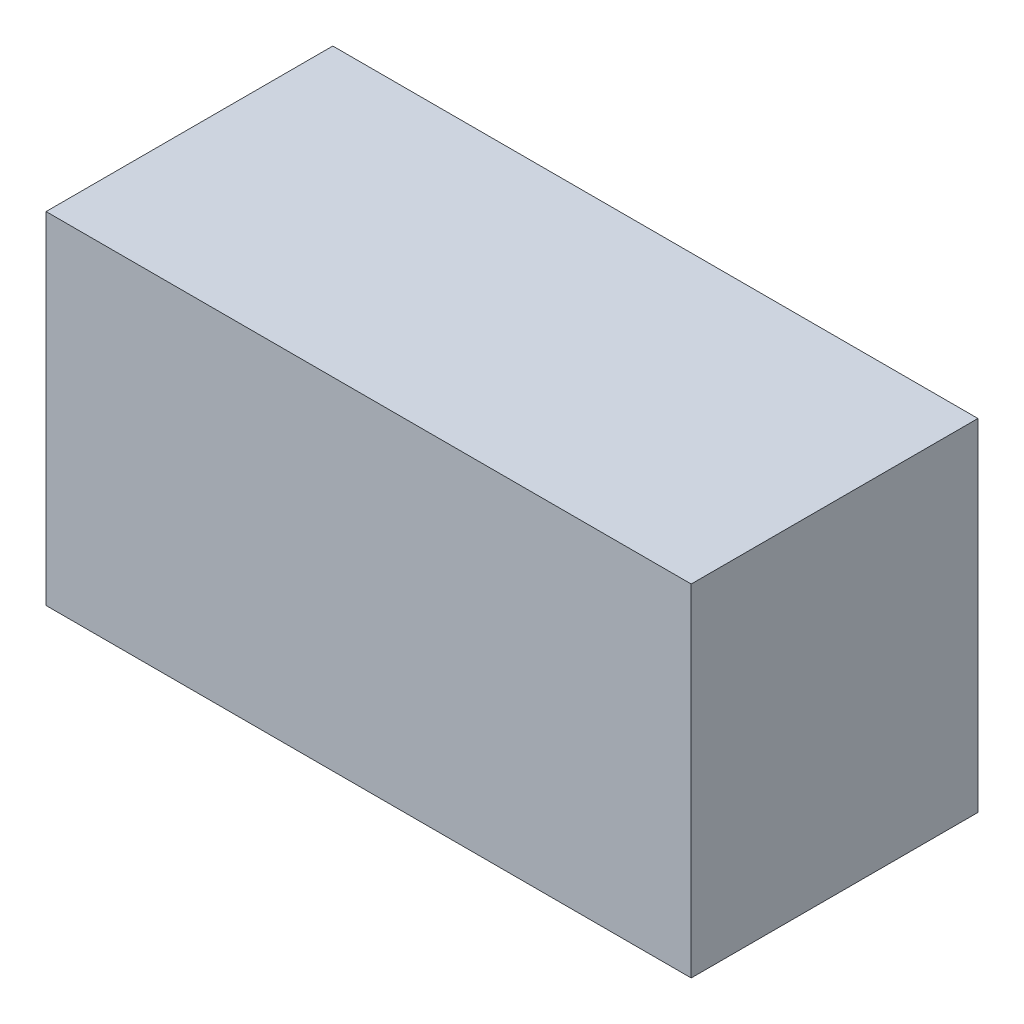
from build123d import *

# Parameters (mm, degrees)
SKETCH1_W           = 22.5
SKETCH1_H           = 11.9
BOSS_EXTRUDE1_DEPTH = 5
SKETCH2_R           = 1.5
BOSS_EXTRUDE2_DEPTH = 4


with BuildPart() as part:
    # Sketch1 → Boss-Extrude1 (new body, symmetric)
    with BuildSketch(Plane.XY):
        Rectangle(SKETCH1_W, SKETCH1_H)
    extrude(amount=BOSS_EXTRUDE1_DEPTH, both=True)

    # Sketch2 → Boss-Extrude2 (add)
    with BuildSketch(Plane(origin=(0, 0, -5), x_dir=(-1, 0, 0), z_dir=(0, 0, -1))):
        Circle(SKETCH2_R)
    extrude(amount=BOSS_EXTRUDE2_DEPTH)


solid = part.part
